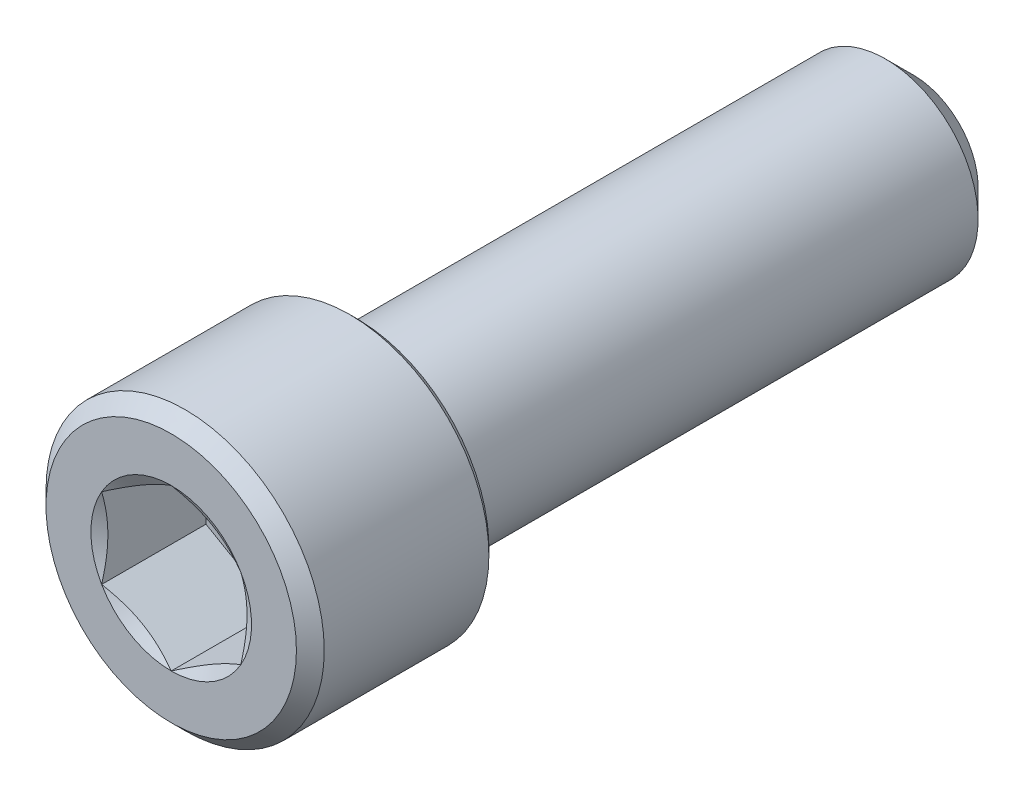
from build123d import *

# Parameters (mm, degrees)
CUT_EXTRUDE1_DEPTH = 3.571875
CHAMFER1_SIZE      = 0.47625
CHAMFER2_SIZE      = 0.238125


with BuildPart() as part:
    # Sketch2 → Revolve1 (revolve)
    with BuildSketch(Plane(origin=(0, 0, 0), x_dir=(0, 0, -1), z_dir=(1, 0, 0))):
        Polygon((12.7, 2.2225), (11.7475, 3.175), (-6.35, 3.175), (-6.35, 4.7625), (-12.7, 4.7625), (-12.7, 0), (12.7, 0), align=None)
    revolve(axis=Axis((0, 0, -12.7), (0, 0, 1)))

    # Sketch4 → Cut-Extrude1 (cut)
    with BuildSketch(Plane.XY.offset(12.7)):
        Polygon((0, 2.749630657), (-2.38125, 1.374815329), (-2.38125, -1.374815329), (0, -2.749630657), (2.38125, -1.374815329), (2.38125, 1.374815329), align=None)
    extrude(amount=-CUT_EXTRUDE1_DEPTH, mode=Mode.SUBTRACT)

    # Cut-Extrude2 cone 1 section (through the dimple's axis) → Cut-Extrude2 (revolve, cut)
    with BuildSketch(Plane(origin=(0, 0, 12.7), x_dir=(0, -1, 0), z_dir=(1, 0, 0))):
        Polygon((0, 0), (2.749630657, 0), (0, 1.5875), align=None)
    revolve(axis=Axis((0, 0, 12.7), (0, 0, -1)), mode=Mode.SUBTRACT)

    # Chamfer1
    chamfer1_edges = [part.edges().sort_by_distance(p)[0] for p in [
        (0, -4.7625, 12.7),
    ]]
    chamfer(chamfer1_edges, length=CHAMFER1_SIZE)

    # Chamfer2
    chamfer2_edges = [part.edges().sort_by_distance(p)[0] for p in [
        (0, -4.7625, 6.35),
    ]]
    chamfer(chamfer2_edges, length=CHAMFER2_SIZE)


solid = part.part
